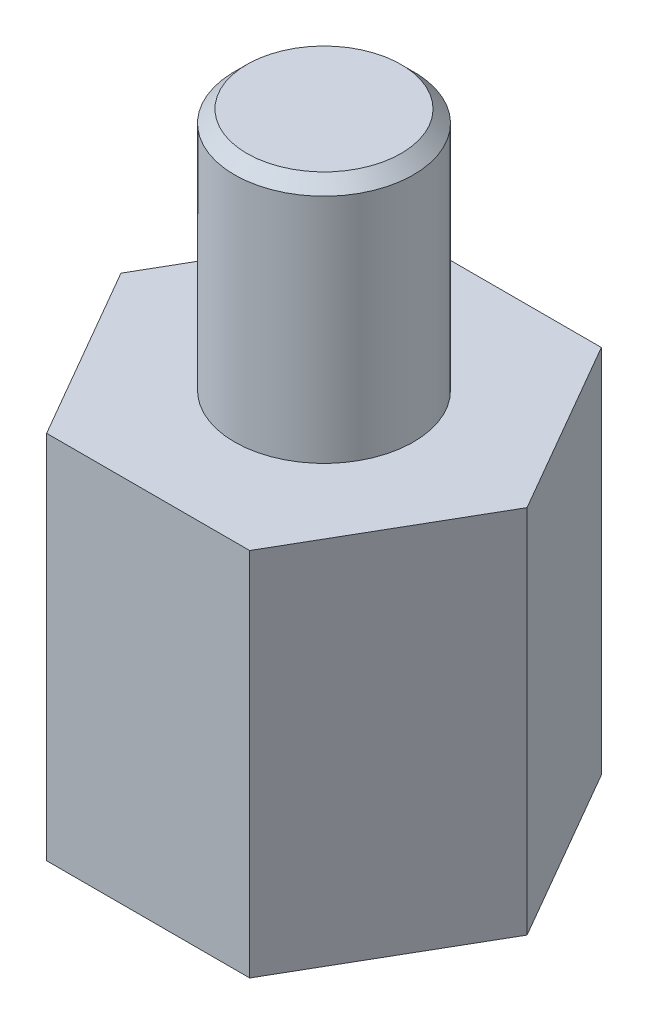
from build123d import *

# Parameters (mm, degrees)
SKETCH1_R           = 1.4
BOSS_EXTRUDE1_DEPTH = 5
BOSS_EXTRUDE2_DEPTH = 1
SKETCH3_R           = 1.45
BOSS_EXTRUDE3_DEPTH = 3.95
CHAMFER1_SIZE       = 0.2


with BuildPart() as part:
    # Sketch1 → Boss-Extrude1 (new body)
    with BuildSketch(Plane(origin=(0, 0, 0), x_dir=(1, 0, 0), z_dir=(0, 1, 0))):
        Polygon((1.645448267, -2.85), (3.290896534, 0), (1.645448267, 2.85), (-1.645448267, 2.85), (-3.290896534, 0), (-1.645448267, -2.85), align=None)
        Circle(SKETCH1_R, mode=Mode.SUBTRACT)
    extrude(amount=BOSS_EXTRUDE1_DEPTH)

    # Sketch2 → Boss-Extrude2 (add)
    with BuildSketch(Plane(origin=(0, 5, 0), x_dir=(1, 0, 0), z_dir=(0, 1, 0))):
        Polygon((-1.645448267, -2.85), (1.645448267, -2.85), (3.290896534, 0), (1.645448267, 2.85), (-1.645448267, 2.85), (-3.290896534, 0), align=None)
    extrude(amount=BOSS_EXTRUDE2_DEPTH)

    # Sketch3 → Boss-Extrude3 (add)
    with BuildSketch(Plane(origin=(0, 6, 0), x_dir=(1, 0, 0), z_dir=(0, 1, 0))):
        Circle(SKETCH3_R)
    extrude(amount=BOSS_EXTRUDE3_DEPTH)

    # Chamfer1
    chamfer1_edges = [part.edges().sort_by_distance(p)[0] for p in [
        (-1.45, 9.95, 0),
    ]]
    chamfer(chamfer1_edges, length=CHAMFER1_SIZE)


solid = part.part
